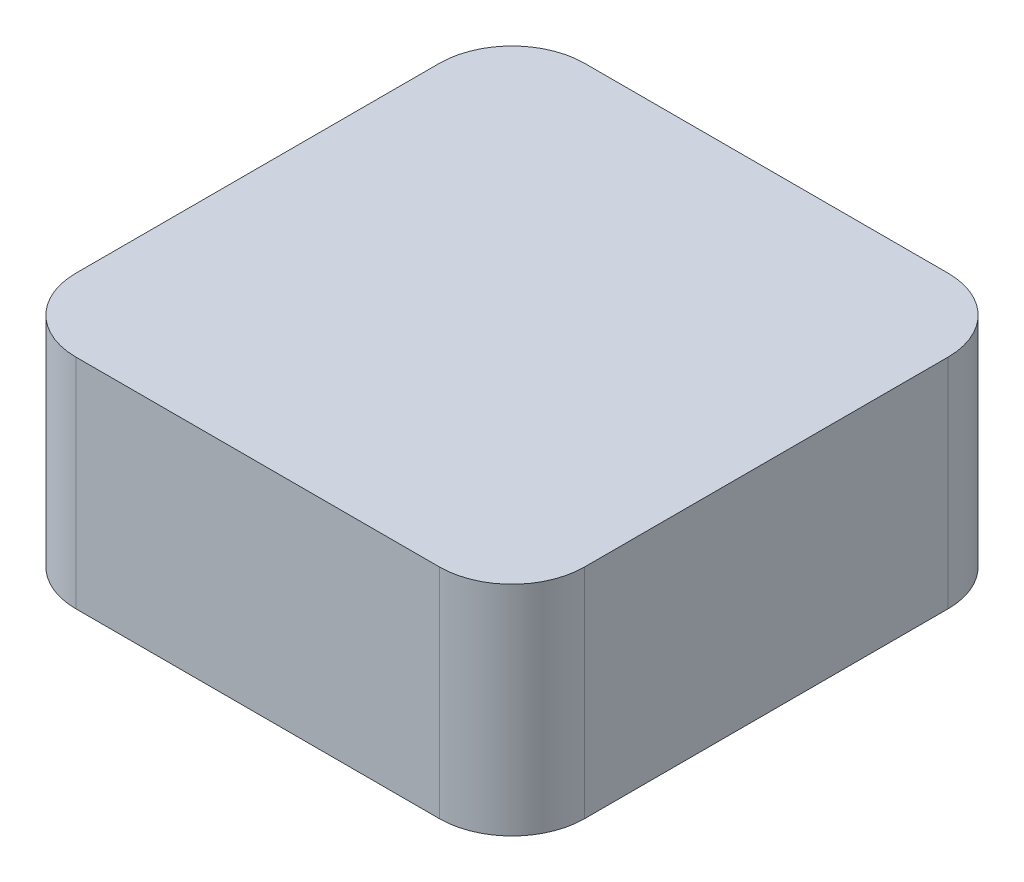
from build123d import *

# Parameters (mm, degrees)
BOSS_EXTRUDE1_DEPTH = 38.1


with BuildPart() as part:
    # Sketch1 → Boss-Extrude1 (new body)
    with BuildSketch(Plane(origin=(0, 0, 0), x_dir=(1, 0, 0), z_dir=(0, 1, 0))):
        with BuildLine():
            Line((-31.75, -44.45), (31.75, -44.45))
            ThreePointArc((31.75, -44.45), (40.730256121, -40.730256121), (44.45, -31.75))
            Line((44.45, -31.75), (44.45, 31.75))
            ThreePointArc((44.45, 31.75), (40.730256121, 40.730256121), (31.75, 44.45))
            Line((31.75, 44.45), (-31.75, 44.45))
            ThreePointArc((-31.75, 44.45), (-40.730256121, 40.730256121), (-44.45, 31.75))
            Line((-44.45, 31.75), (-44.45, -31.75))
            ThreePointArc((-44.45, -31.75), (-40.730256121, -40.730256121), (-31.75, -44.45))
        make_face()
    extrude(amount=BOSS_EXTRUDE1_DEPTH)


solid = part.part
